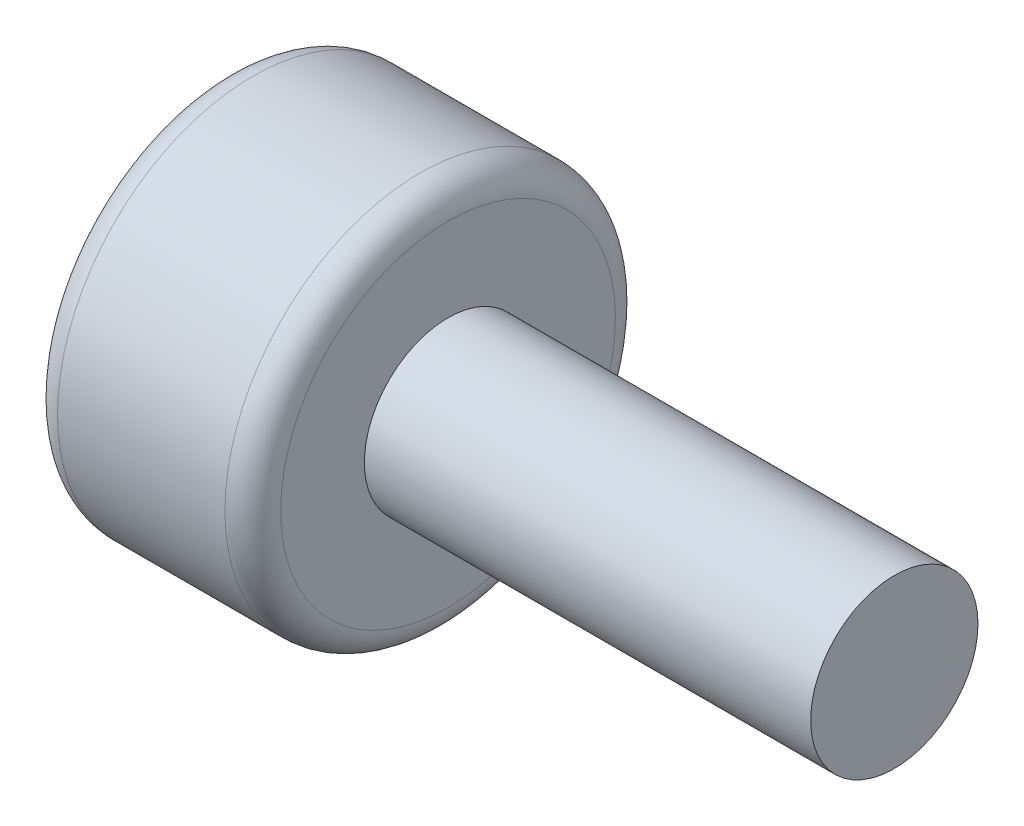
from build123d import *

# Parameters (mm, degrees)
SKETCH1_R           = 3.5
BOSS_EXTRUDE1_DEPTH = 4
SKETCH2_R           = 1.5
BOSS_EXTRUDE2_DEPTH = 8
CUT_EXTRUDE1_DEPTH  = 2
FILLET1_R           = 0.5


with BuildPart() as part:
    # Sketch1 → Boss-Extrude1 (new body)
    with BuildSketch(Plane(origin=(0, 0, 0), x_dir=(0, 0, -1), z_dir=(1, 0, 0))):
        Circle(SKETCH1_R)
    extrude(amount=BOSS_EXTRUDE1_DEPTH)

    # Sketch2 → Boss-Extrude2 (add)
    with BuildSketch(Plane(origin=(4, 0, 0), x_dir=(0, 0, -1), z_dir=(1, 0, 0))):
        Circle(SKETCH2_R)
    extrude(amount=BOSS_EXTRUDE2_DEPTH)

    # Sketch3 → Cut-Extrude1 (cut)
    with BuildSketch(Plane.ZY):
        Polygon((0, 1.732050808), (-1.5, 0.866025404), (-1.5, -0.866025404), (0, -1.732050808), (1.5, -0.866025404), (1.5, 0.866025404), align=None)
    extrude(amount=-CUT_EXTRUDE1_DEPTH, mode=Mode.SUBTRACT)

    # Fillet1
    fillet1_edges = [part.edges().sort_by_distance(p)[0] for p in [
        (0, 0, 3.5),
        (4, 0, 3.5),
    ]]
    fillet(fillet1_edges, radius=FILLET1_R)


solid = part.part
